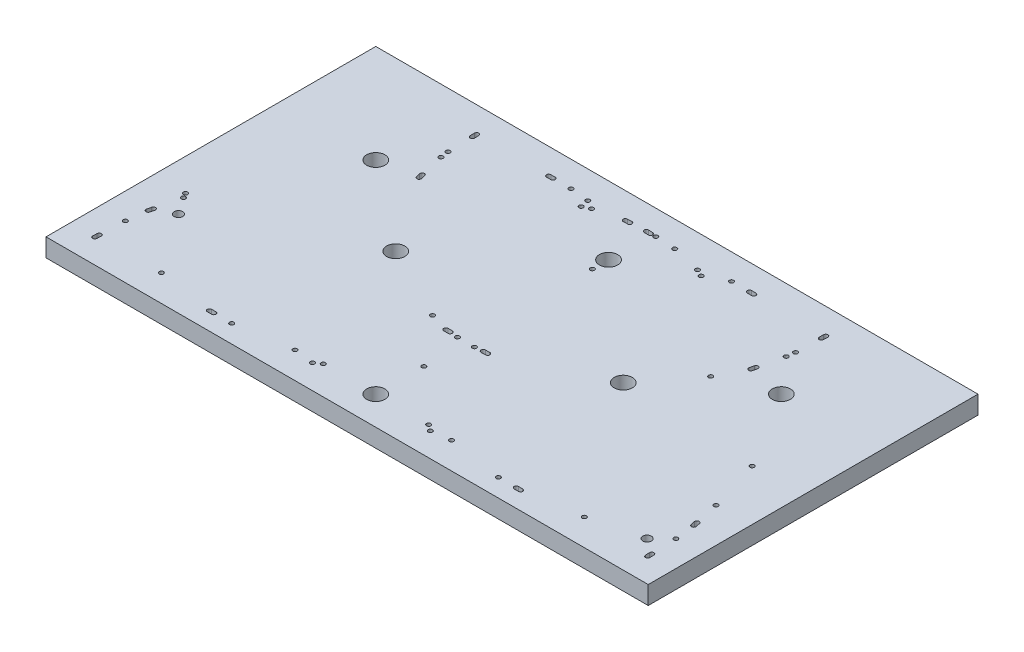
from build123d import *

# Parameters (mm, degrees)
SKETCH1_W           = 420
SKETCH1_H           = 230
BOSS_EXTRUDE1_DEPTH = 12.7
SKETCH7_R           = 6.35
SKETCH7_R_2         = 1.5
SKETCH7_R_3         = 3
CUT_EXTRUDE1_DEPTH  = 12.7
SKETCH8_R           = 1.5
SKETCH8_R_2         = 6.35
CUT_EXTRUDE2_DEPTH  = 12.7


with BuildPart() as part:
    # Sketch1 → Boss-Extrude1 (new body)
    with BuildSketch(Plane(origin=(0, 0, 0), x_dir=(1, 0, 0), z_dir=(0, 1, 0))):
        with Locations((210, 115)):
            Rectangle(SKETCH1_W, SKETCH1_H)
    extrude(amount=BOSS_EXTRUDE1_DEPTH)

    # Sketch7 → Cut-Extrude1 (cut)
    with BuildSketch(Plane(origin=(196.460458651, 12.7, -62.603037437), x_dir=(0.090258341, 0, 0.995918386), z_dir=(0, 1, 0))):
        with Locations(Location((43.651204827, 9.638998703, 0), (0, 0, 354.82153059))):  # turned: the seam where the file's is
            Circle(SKETCH7_R)
        with Locations(Location((-109.957381, -118.440673222, 0), (0, 0, 354.82153059))):  # turned: the seam where the file's is
            Circle(SKETCH7_R)
        with Locations(Location((43.099653048, -31.508080441, 0), (0, 0, 354.82153059))):  # turned: the seam where the file's is
            Circle(SKETCH7_R_2)
        with Locations(Location((9.106186641, -179.974138285, 0), (0, 0, 354.82153059))):  # turned: the seam where the file's is
            Circle(SKETCH7_R_2)
        with Locations(Location((42.72656704, -83.658348767, 0), (0, 0, 354.82153059))):  # turned: the seam where the file's is
            Circle(SKETCH7_R_2)
        with Locations(Location((59.514618406, 101.582471063, 0), (0, 0, 354.82153059))):  # turned: the seam where the file's is
            Circle(SKETCH7_R_2)
        with Locations(Location((9.106186641, 199.252135691, 0), (0, 0, 354.82153059))):  # turned: the seam where the file's is
            Circle(SKETCH7_R_2)
        with Locations(Location((-146.11085778, 43.356347284, 0), (0, 0, 354.82153059))):  # turned: the seam where the file's is
            Circle(SKETCH7_R_2)
        with Locations(Location((46.986103661, 46.369904384, 0), (0, 0, 354.82153059))):  # turned: the seam where the file's is
            Circle(SKETCH7_R_2)
        with Locations(Location((31.778994905, -137.978961535, 0), (0, 0, 354.82153059))):  # turned: the seam where the file's is
            Circle(SKETCH7_R_2)
        with Locations(Location((40.195997242, -45.105025216, 0), (0, 0, 354.82153059))):  # turned: the seam where the file's is
            Circle(SKETCH7_R_2)
        with Locations(Location((50.040444185, 63.519459099, 0), (0, 0, 354.82153059))):  # turned: the seam where the file's is
            Circle(SKETCH7_R_2)
        with Locations(Location((58.404584222, 155.810108196, 0), (0, 0, 354.82153059))):  # turned: the seam where the file's is
            Circle(SKETCH7_R_2)
        with Locations(Location((10.28793889, 12.662653116, 0), (0, 0, 354.82153059))):  # turned: the seam where the file's is
            Circle(SKETCH7_R_2)
        with Locations(Location((40.359061234, -26.859260892, 0), (0, 0, 354.82153059))):  # turned: the seam where the file's is
            Circle(SKETCH7_R_2)
        with Locations(Location((50.526634497, 50.371125536, 0), (0, 0, 354.82153059))):  # turned: the seam where the file's is
            Circle(SKETCH7_R_2)
        with Locations(Location((-84.428467098, 163.24758453, 0), (0, 0, 354.82153059))):  # turned: the seam where the file's is
            Circle(SKETCH7_R)
        with Locations(Location((-27.999784998, 191.535633244, 0), (0, 0, 354.82153059))):  # turned: the seam where the file's is
            Circle(SKETCH7_R_2)
        with Locations(Location((-150.176265572, -15.878871876, 0), (0, 0, 354.82153059))):  # turned: the seam where the file's is
            Circle(SKETCH7_R_2)
        with Locations(Location((-27.999784998, -172.257635837, 0), (0, 0, 354.82153059))):  # turned: the seam where the file's is
            Circle(SKETCH7_R_2)
        with Locations(Location((-12.157521123, -163.593175294, 0), (0, 0, 354.82153059))):  # turned: the seam where the file's is
            Circle(SKETCH7_R_3)
        with Locations(Location((52.722508699, 191.41279067, 0), (0, 0, 354.82153059))):  # turned: the seam where the file's is
            Circle(SKETCH7_R_3)
        with Locations(Location((-24.419594065, -170.674246341, 0), (0, 0, 354.82153059))):  # turned: the seam where the file's is
            Circle(SKETCH7_R_2)
        with Locations(Location((-148.050944539, 29.558484854, 0), (0, 0, 354.82153059))):  # turned: the seam where the file's is
            Circle(SKETCH7_R_2)
        with Locations(Location((43.757660715, 202.373242332, 0), (0, 0, 354.82153059))):  # turned: the seam where the file's is
            Circle(SKETCH7_R_2)
        with BuildLine():
            Line((62.407500266, 116.883818538), (62.136725244, 113.896063379))
            ThreePointArc((62.136725244, 113.896063379), (60.507460154, 112.537573311), (59.148970086, 114.166838401))
            Line((59.148970086, 114.166838401), (59.419745108, 117.15459356))
            ThreePointArc((59.419745108, 117.15459356), (61.049010198, 118.513083628), (62.407500266, 116.883818538))
        make_face()
        with BuildLine():
            Line((39.83368518, -98.959696242), (40.104460202, -95.971941083))
            ThreePointArc((40.104460202, -95.971941083), (41.733725292, -94.613451015), (43.09221536, -96.242716105))
            Line((43.09221536, -96.242716105), (42.821440338, -99.230471264))
            ThreePointArc((42.821440338, -99.230471264), (41.192175248, -100.588961332), (39.83368518, -98.959696242))
        make_face()
        with BuildLine():
            Line((29.626595588, 200.44075534), (26.652261004, 200.049176763))
            ThreePointArc((26.652261004, 200.049176763), (24.969304423, 201.340554767), (26.260682427, 203.023511347))
            Line((26.260682427, 203.023511347), (29.235017011, 203.415089924))
            ThreePointArc((29.235017011, 203.415089924), (30.917973591, 202.12371192), (29.626595588, 200.44075534))
        make_face()
        with BuildLine():
            Line((-150.185944072, 23.209544269), (-149.807347164, 26.185559118))
            ThreePointArc((-149.807347164, 26.185559118), (-148.130041286, 27.484268089), (-146.831332315, 25.806962211))
            Line((-146.831332315, 25.806962211), (-147.209929223, 22.830947362))
            ThreePointArc((-147.209929223, 22.830947362), (-148.887235101, 21.532238391), (-150.185944072, 23.209544269))
        make_face()
        with BuildLine():
            Line((29.235017011, -184.137092518), (26.260682427, -183.745513941))
            ThreePointArc((26.260682427, -183.745513941), (24.969304423, -182.062557361), (26.652261004, -180.771179357))
            Line((26.652261004, -180.771179357), (29.626595588, -181.162757934))
            ThreePointArc((29.626595588, -181.162757934), (30.917973591, -182.845714514), (29.235017011, -184.137092518))
        make_face()
        with BuildLine():
            Line((64.155240602, 199.851371503), (61.159179013, 200.00504307))
            ThreePointArc((61.159179013, 200.00504307), (59.737984001, 201.579909648), (61.312850579, 203.001104659))
            Line((61.312850579, 203.001104659), (64.308912169, 202.847433093))
            ThreePointArc((64.308912169, 202.847433093), (65.73010718, 201.272566515), (64.155240602, 199.851371503))
        make_face()
        with BuildLine():
            Line((-150.655606189, 9.165217681), (-150.501934623, 12.161279271))
            ThreePointArc((-150.501934623, 12.161279271), (-148.927068045, 13.582474283), (-147.505873033, 12.007607705))
            Line((-147.505873033, 12.007607705), (-147.659544599, 9.011546115))
            ThreePointArc((-147.659544599, 9.011546115), (-149.234411177, 7.590351103), (-150.655606189, 9.165217681))
        make_face()
        with BuildLine():
            Line((-5.367140889, -178.388131742), (-8.222616285, -177.468207688))
            ThreePointArc((-8.222616285, -177.468207688), (-9.190391955, -175.580507963), (-7.302692231, -174.612732292))
            Line((-7.302692231, -174.612732292), (-4.447216835, -175.532656346))
            ThreePointArc((-4.447216835, -175.532656346), (-3.479441164, -177.420356071), (-5.367140889, -178.388131742))
        make_face()
    extrude(amount=-CUT_EXTRUDE1_DEPTH, mode=Mode.SUBTRACT)

    # Sketch8 → Cut-Extrude2 (cut)
    with BuildSketch(Plane(origin=(196.460458651, 12.7, -62.603037437), x_dir=(0.090258341, 0, 0.995918386), z_dir=(0, 1, 0))):
        with BuildLine():
            Line((-155.341291075, -41.107395995), (-155.612066097, -44.095151153))
            ThreePointArc((-155.612066097, -44.095151153), (-154.253576029, -45.724416243), (-152.624310939, -44.365926175))
            Line((-152.624310939, -44.365926175), (-152.353535917, -41.378171017))
            ThreePointArc((-152.353535917, -41.378171017), (-153.712025985, -39.748905926), (-155.341291075, -41.107395995))
        make_face()
        with BuildLine():
            Line((-139.988143243, 95.06264789), (-139.717368221, 98.050403049))
            ThreePointArc((-139.717368221, 98.050403049), (-141.075858289, 99.679668139), (-142.70512338, 98.321178071))
            Line((-142.70512338, 98.321178071), (-142.975898402, 95.333422913))
            ThreePointArc((-142.975898402, 95.333422913), (-141.617408333, 93.704157822), (-139.988143243, 95.06264789))
        make_face()
        with BuildLine():
            Line((-133.470950384, 149.377017265), (-136.44954449, 149.734756204))
            ThreePointArc((-136.44954449, 149.734756204), (-138.117711013, 148.42432862), (-136.807283429, 146.756162098))
            Line((-136.807283429, 146.756162098), (-133.828689323, 146.398423159))
            ThreePointArc((-133.828689323, 146.398423159), (-132.1605228, 147.708850742), (-133.470950384, 149.377017265))
        make_face()
        with BuildLine():
            Line((-94.516002831, 137.554448495), (-91.671170318, 136.602120835))
            ThreePointArc((-91.671170318, 136.602120835), (-89.772590232, 137.548373261), (-90.718842658, 139.446953348))
            Line((-90.718842658, 139.446953348), (-93.563675172, 140.399281008))
            ThreePointArc((-93.563675172, 140.399281008), (-95.462255258, 139.453028581), (-94.516002831, 137.554448495))
        make_face()
        with BuildLine():
            Line((-22.005535505, 4.048213218), (-22.363274444, 1.069619111))
            ThreePointArc((-22.363274444, 1.069619111), (-21.05284686, -0.598547411), (-19.384680337, 0.711880173))
            Line((-19.384680337, 0.711880173), (-19.026941398, 3.690474279))
            ThreePointArc((-19.026941398, 3.690474279), (-20.337368982, 5.358640802), (-22.005535505, 4.048213218))
        make_face()
        with BuildLine():
            Line((-16.936292811, 26.75887274), (-16.752711763, 29.753250471))
            ThreePointArc((-16.752711763, 29.753250471), (-18.158110106, 31.342229861), (-19.747089495, 29.936831519))
            Line((-19.747089495, 29.936831519), (-19.930670542, 26.942453787))
            ThreePointArc((-19.930670542, 26.942453787), (-18.5252722, 25.353474398), (-16.936292811, 26.75887274))
        make_face()
        with BuildLine():
            Line((-155.523578437, -92.984871409), (-158.517956168, -92.801290362))
            ThreePointArc((-158.517956168, -92.801290362), (-160.106935557, -94.206688704), (-158.701537215, -95.795668093))
            Line((-158.701537215, -95.795668093), (-155.707159484, -95.979249141))
            ThreePointArc((-155.707159484, -95.979249141), (-154.118180094, -94.573850798), (-155.523578437, -92.984871409))
        make_face()
        with BuildLine():
            Line((-114.836082574, -94.32231359), (-111.86639195, -93.896945988))
            ThreePointArc((-111.86639195, -93.896945988), (-110.594230439, -92.199416875), (-112.291759552, -90.927255364))
            Line((-112.291759552, -90.927255364), (-115.261450176, -91.352622966))
            ThreePointArc((-115.261450176, -91.352622966), (-116.533611687, -93.050152079), (-114.836082574, -94.32231359))
        make_face()
        with Locations(Location((-136.672463224, 68.211664221, 0), (0, 0, 354.82153059))):  # turned: the seam where the file's is
            Circle(SKETCH8_R)
        with Locations(Location((-138.148165526, -95.552949717, 0), (0, 0, 354.82153059))):  # turned: the seam where the file's is
            Circle(SKETCH8_R)
        with Locations(Location((-117.99733388, 24.288922913, 0), (0, 0, 354.82153059))):  # turned: the seam where the file's is
            Circle(SKETCH8_R_2)
        with Locations(Location((-146.072836923, -10.057415973, 0), (0, 0, 354.82153059))):  # turned: the seam where the file's is
            Circle(SKETCH8_R)
        with Locations(Location((-152.719184237, -28.793803678, 0), (0, 0, 354.82153059))):  # turned: the seam where the file's is
            Circle(SKETCH8_R)
        with Locations(Location((-25.927889983, -11.95113928, 0), (0, 0, 354.82153059))):  # turned: the seam where the file's is
            Circle(SKETCH8_R)
        with Locations(Location((-19.504371119, 9.38345983, 0), (0, 0, 354.82153059))):  # turned: the seam where the file's is
            Circle(SKETCH8_R)
        with Locations(Location((-42.026898399, 97.079200046, 0), (0, 0, 354.82153059))):  # turned: the seam where the file's is
            Circle(SKETCH8_R_2)
        with Locations(Location((-73.67231149, 126.774257586, 0), (0, 0, 354.82153059))):  # turned: the seam where the file's is
            Circle(SKETCH8_R)
        with Locations(Location((-56.350922478, -60.97332825, 0), (0, 0, 354.82153059))):  # turned: the seam where the file's is
            Circle(SKETCH8_R_2)
        with Locations(Location((-110.634695329, 144.532109434, 0), (0, 0, 354.82153059))):  # turned: the seam where the file's is
            Circle(SKETCH8_R)
        with Locations(Location((-142.610250081, 82.749055574, 0), (0, 0, 354.82153059))):  # turned: the seam where the file's is
            Circle(SKETCH8_R)
        with Locations(Location((-106.832063326, 23.27703398, 0), (0, 0, 354.82153059))):  # turned: the seam where the file's is
            Circle(SKETCH8_R)
        with Locations(Location((-144.241934154, -15.190869086, 0), (0, 0, 354.82153059))):  # turned: the seam where the file's is
            Circle(SKETCH8_R)
        with Locations(Location((-139.415073739, 63.539716428, 0), (0, 0, 354.82153059))):  # turned: the seam where the file's is
            Circle(SKETCH8_R)
        with Locations(Location((-116.274687565, 145.800909735, 0), (0, 0, 354.82153059))):  # turned: the seam where the file's is
            Circle(SKETCH8_R)
        with Locations(Location((-18.429427974, 21.244476037, 0), (0, 0, 354.82153059))):  # turned: the seam where the file's is
            Circle(SKETCH8_R)
        with Locations(Location((-132.371961683, -95.318779291, 0), (0, 0, 354.82153059))):  # turned: the seam where the file's is
            Circle(SKETCH8_R)
    extrude(amount=-CUT_EXTRUDE2_DEPTH, mode=Mode.SUBTRACT)


solid = part.part
